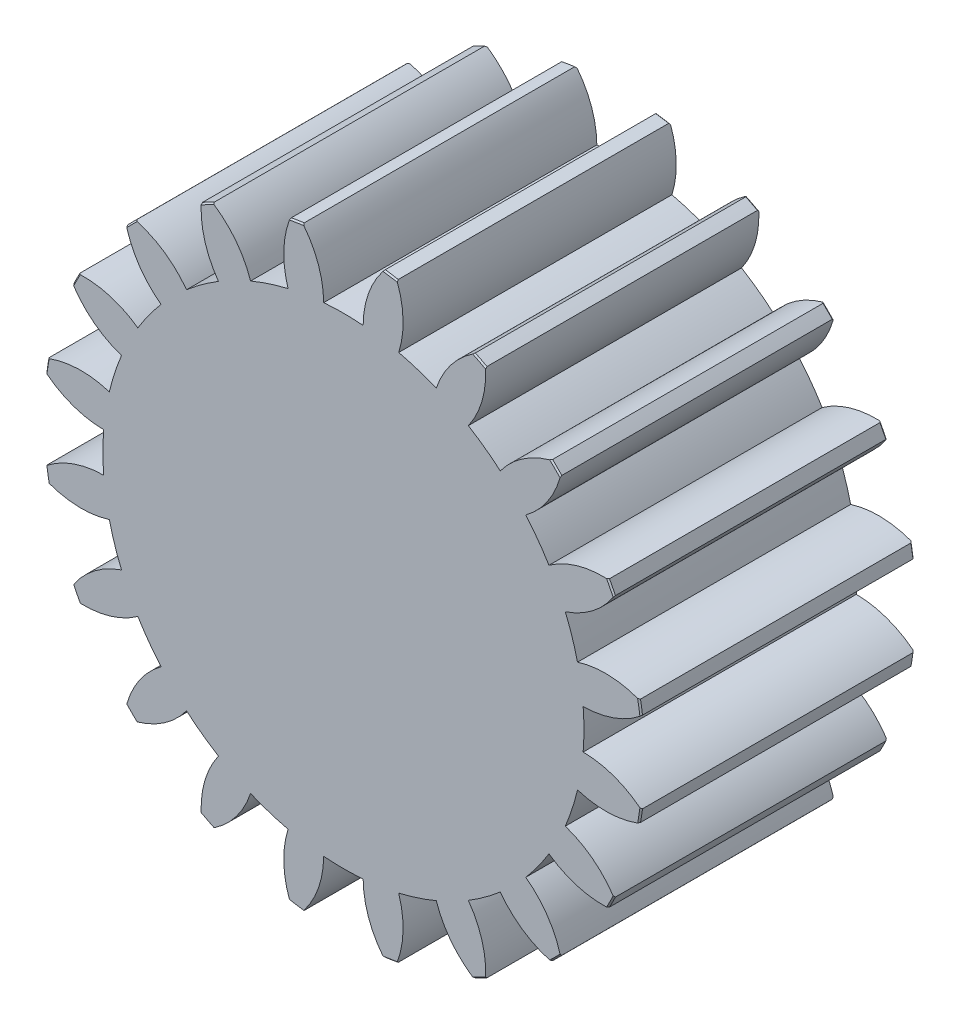
from build123d import *

# Parameters (mm, degrees)
SKETCH2_R                = 22
BOSS_EXTRUDE1_DEPTH      = 10
CUT_EXTRUDE1_DEPTH       = 10
FILLET1_R                = 0.6
CHAMFER1_SIZE            = 0.1
CIRPATTERN1_COUNT        = 20
FILLET1_OF_CIRPATTERN1_R = 0.6
CUT_EXTRUDE3_DEPTH       = 21
CIRPATTERN2_COUNT        = 20


with BuildPart() as part:
    # Sketch2 → Boss-Extrude1 (new body, symmetric)
    with BuildSketch(Plane.XY):
        Circle(SKETCH2_R)
    extrude(amount=BOSS_EXTRUDE1_DEPTH, both=True)

    # Sketch3 → Cut-Extrude1 (cut)
    with BuildSketch(Plane.XY.offset(10)):
        with BuildLine():
            ThreePointArc((1.155064539, 17.962901378), (0, 18), (-1.155064539, 17.962901378))
            ThreePointArc((-1.155064539, 17.962901378), (-1.596564099, 20.012299891), (-2.616561789, 21.843845916))
            ThreePointArc((-2.616561789, 21.843845916), (0, 22), (2.616561789, 21.843845916))
            ThreePointArc((2.616561789, 21.843845916), (1.596564099, 20.012299891), (1.155064539, 17.962901378))
        make_face()
    cut_extrude1 = extrude(amount=-CUT_EXTRUDE1_DEPTH, mode=Mode.SUBTRACT)

    # Fillet1
    fillet1_edges = [part.edges().sort_by_distance(p)[0] for p in [
        (-1.155064539, 17.962901378, 5),
        (1.155064539, 17.962901378, 5),
    ]]
    fillet(fillet1_edges, radius=FILLET1_R)

    # Chamfer1
    chamfer1_edges = [part.edges().sort_by_distance(p)[0] for p in [
        (-22, 0, -10),
        (-14.601980014, -16.455460482, 10),
    ]]
    chamfer(chamfer1_edges, length=CHAMFER1_SIZE)

    # CirPattern1: Cut-Extrude1 ×20 about axis
    cirpattern1_axis = Axis((0, 0, 0), (0, 0, 1))
    for i in range(1, CIRPATTERN1_COUNT):
        add(cut_extrude1.rotate(cirpattern1_axis, i * 360 / CIRPATTERN1_COUNT), mode=Mode.SUBTRACT)

    # Fillet1 of CirPattern1
    fillet1_of_cirpattern1_edges = [part.edges().sort_by_distance(p)[0] for p in [
        (-6.649373451, 16.726799835, 5),
        (-4.452310137, 17.440668979, 5),
        (-11.49279536, 13.853362581, 5),
        (-9.623861676, 15.211222385, 5),
        (-15.211222385, 9.623861676, 5),
        (-13.853362581, 11.49279536, 5),
        (-17.440668979, 4.452310137, 5),
        (-16.726799835, 6.649373451, 5),
        (-17.962901378, -1.155064539, 5),
        (-17.962901378, 1.155064539, 5),
        (-16.726799835, -6.649373451, 5),
        (-17.440668979, -4.452310137, 5),
        (-13.853362581, -11.49279536, 5),
        (-15.211222385, -9.623861676, 5),
        (-9.623861676, -15.211222385, 5),
        (-11.49279536, -13.853362581, 5),
        (-4.452310137, -17.440668979, 5),
        (-6.649373451, -16.726799835, 5),
        (1.155064539, -17.962901378, 5),
        (-1.155064539, -17.962901378, 5),
        (6.649373451, -16.726799835, 5),
        (4.452310137, -17.440668979, 5),
        (11.49279536, -13.853362581, 5),
        (9.623861676, -15.211222385, 5),
        (15.211222385, -9.623861676, 5),
        (13.853362581, -11.49279536, 5),
        (17.440668979, -4.452310137, 5),
        (16.726799835, -6.649373451, 5),
        (17.962901378, 1.155064539, 5),
        (17.962901378, -1.155064539, 5),
        (16.726799835, 6.649373451, 5),
        (17.440668979, 4.452310137, 5),
        (13.853362581, 11.49279536, 5),
        (15.211222385, 9.623861676, 5),
        (9.623861676, 15.211222385, 5),
        (11.49279536, 13.853362581, 5),
        (4.452310137, 17.440668979, 5),
        (6.649373451, 16.726799835, 5),
    ]]
    fillet(fillet1_of_cirpattern1_edges, radius=FILLET1_OF_CIRPATTERN1_R)

    # Sketch6 → Cut-Extrude3 (cut, through all)
    with BuildSketch(Plane.XY.offset(10)):
        with BuildLine():
            Line((-2.968996641, 21.798739848), (-2.398118172, 24.056968699))
            Line((-2.398118172, 24.056968699), (2.778480736, 23.660222067))
            Line((2.778480736, 23.660222067), (2.968996641, 21.798739848))
            ThreePointArc((2.968996641, 21.798739848), (1.844757088, 19.805225799), (1.444976463, 17.55174221))
            ThreePointArc((1.444976463, 17.55174221), (0, 17.611121815), (-1.444976463, 17.55174221))
            ThreePointArc((-1.444976463, 17.55174221), (-1.844757088, 19.805225799), (-2.968996641, 21.798739848))
        make_face()
    cut_extrude3 = extrude(amount=-CUT_EXTRUDE3_DEPTH, mode=Mode.SUBTRACT)

    # CirPattern2: Cut-Extrude3 ×20 about axis
    cirpattern2_axis = Axis((0, 0, 0), (0, 0, 1))
    for i in range(1, CIRPATTERN2_COUNT):
        add(cut_extrude3.rotate(cirpattern2_axis, i * 360 / CIRPATTERN2_COUNT), mode=Mode.SUBTRACT)


solid = part.part
